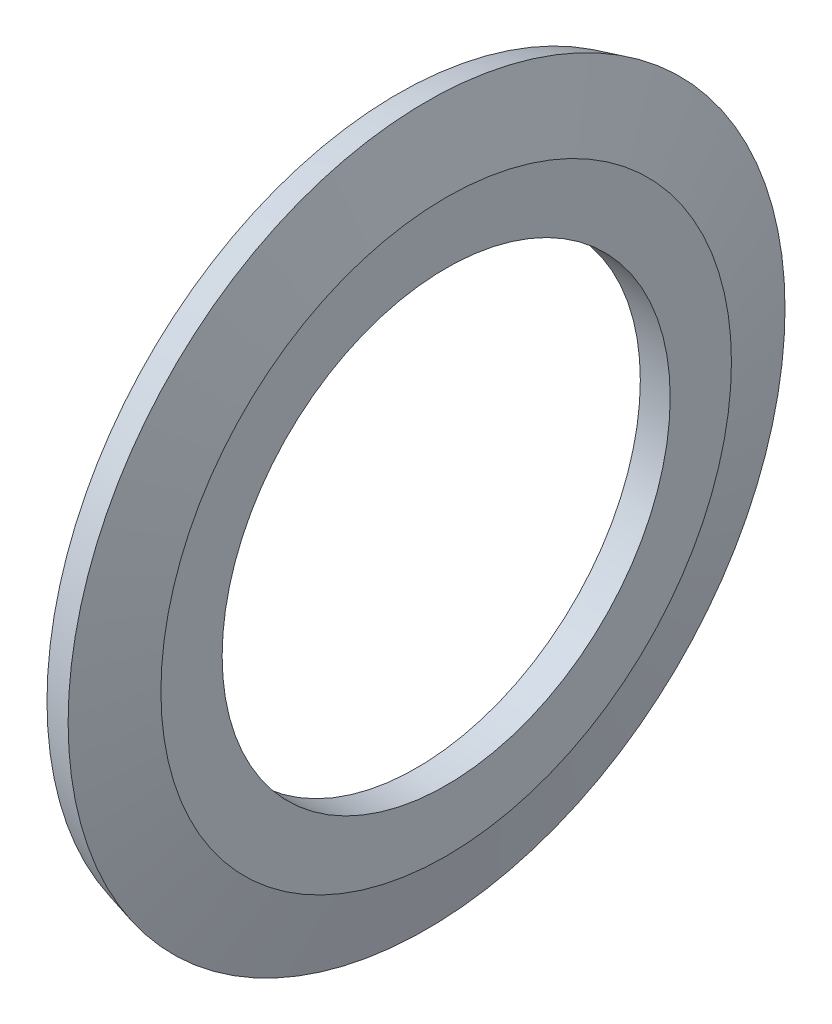
from build123d import *


with BuildPart() as part:
    # Sketch1 → Revolve1 (revolve)
    with BuildSketch(Plane.XY):
        Polygon((0, 7.5), (0, 9.418347502), (-0.622401348, 11.741180955), (0.343524479, 12), (1, 9.55), (1, 7.5), align=None)
    revolve(axis=Axis((0, 0, 0), (1, 0, 0)))


solid = part.part
